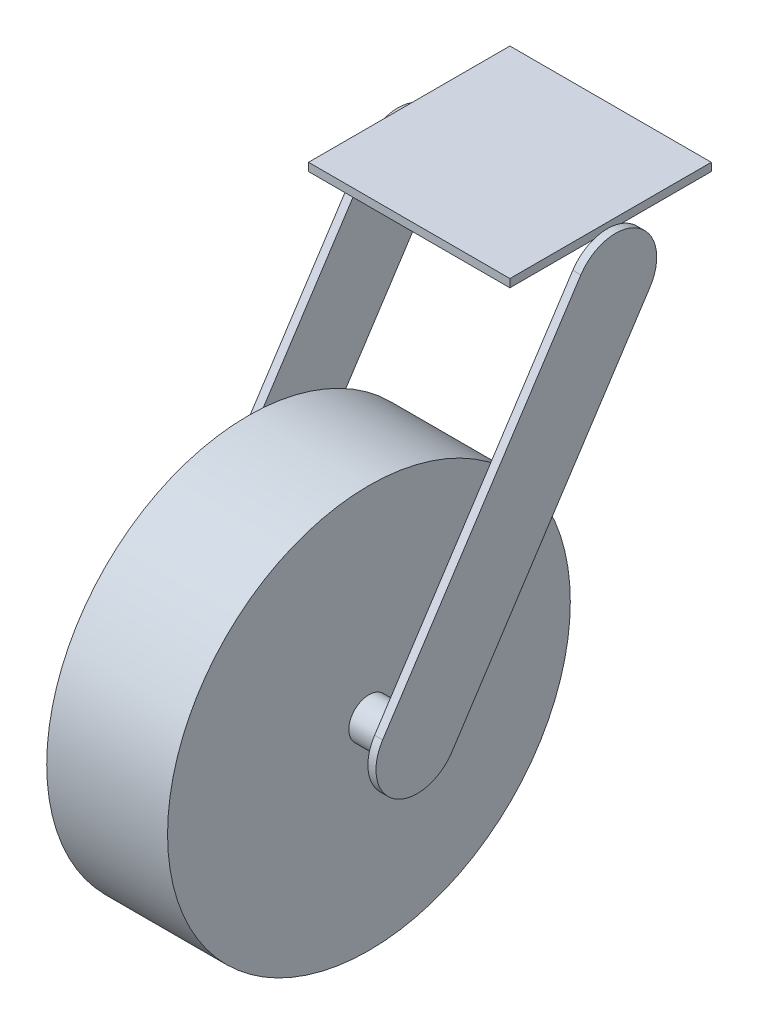
from build123d import *

# Parameters (mm, degrees)
BOSS_EXTRUDE2_DEPTH      = 30
BOSS_EXTRUDE2_DEPTH_BACK = 30
SKETCH1_R                = 100
SKETCH2_R                = 10
BOSS_EXTRUDE3_DEPTH      = 20
BOSS_EXTRUDE4_START      = 20
SKETCH3_R                = 10
BOSS_EXTRUDE4_DEPTH      = 20
BOSS_EXTRUDE5_DEPTH      = 4
SKETCH10_W               = 100
SKETCH10_H               = 100
BOSS_EXTRUDE6_DEPTH      = 4


with BuildPart() as part:
    # Sketch1 → Boss-Extrude2 (new, two sides: drawn at the far end of the back side and taken through both)
    with BuildSketch(Plane(origin=(0, 0, 0), x_dir=(0, 0, -1), z_dir=(1, 0, 0)).offset(-BOSS_EXTRUDE2_DEPTH_BACK)):
        Circle(SKETCH1_R)
    extrude(amount=BOSS_EXTRUDE2_DEPTH + BOSS_EXTRUDE2_DEPTH_BACK)

    # Sketch2 → Boss-Extrude3 (add)
    with BuildSketch(Plane(origin=(30, 0, 0), x_dir=(0, 0, -1), z_dir=(1, 0, 0))):
        Circle(SKETCH2_R)
    extrude(amount=BOSS_EXTRUDE3_DEPTH)

    # Sketch3 → Boss-Extrude4 (add)
    with BuildSketch(Plane.ZY.offset(30).offset(BOSS_EXTRUDE4_START)):
        Circle(SKETCH3_R)
    extrude(amount=-BOSS_EXTRUDE4_DEPTH)

    # Sketch5 → Boss-Extrude5 (add)
    with BuildSketch(Plane.ZY.offset(50)):
        with BuildLine():
            Line((-17.1736092, -11.211866262), (-115.573756817, 139.51109466))
            ThreePointArc((-115.573756817, 139.51109466), (-109.612013879, 167.896570122), (-81.226538417, 161.934827183))
            Line((-81.226538417, 161.934827183), (17.1736092, 11.211866262))
            ThreePointArc((17.1736092, 11.211866262), (11.211866262, -17.1736092), (-17.1736092, -11.211866262))
        make_face()
    boss_extrude5 = extrude(amount=BOSS_EXTRUDE5_DEPTH)

    # Mirror1: Boss-Extrude5 across plane
    add(boss_extrude5.mirror(Plane(origin=(0, 0, 0), x_dir=(0, 0, 1), z_dir=(1, 0, 0))))

    # Sketch10 → Boss-Extrude6 (add)
    with BuildSketch(Plane(origin=(0, 170, 0), x_dir=(1, 0, 0), z_dir=(0, 1, 0))):
        with Locations((0, 100)):
            Rectangle(SKETCH10_W, SKETCH10_H)
    extrude(amount=BOSS_EXTRUDE6_DEPTH)


solid = part.part
